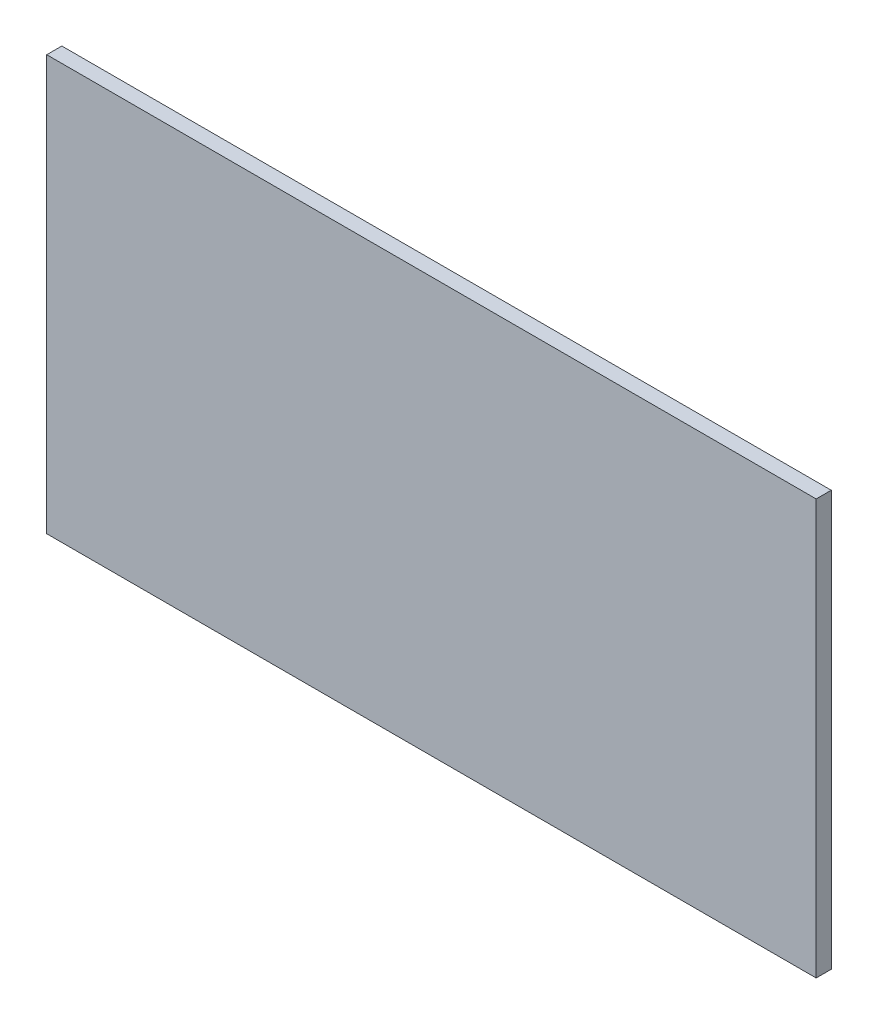
from build123d import *

# Parameters (mm, degrees)
SKETCH1_W           = 510
SKETCH1_H           = 275
BOSS_EXTRUDE1_DEPTH = 10


with BuildPart() as part:
    # Sketch1 → Boss-Extrude1 (new body)
    with BuildSketch(Plane.XY):
        Rectangle(SKETCH1_W, SKETCH1_H)
    extrude(amount=BOSS_EXTRUDE1_DEPTH)


solid = part.part
